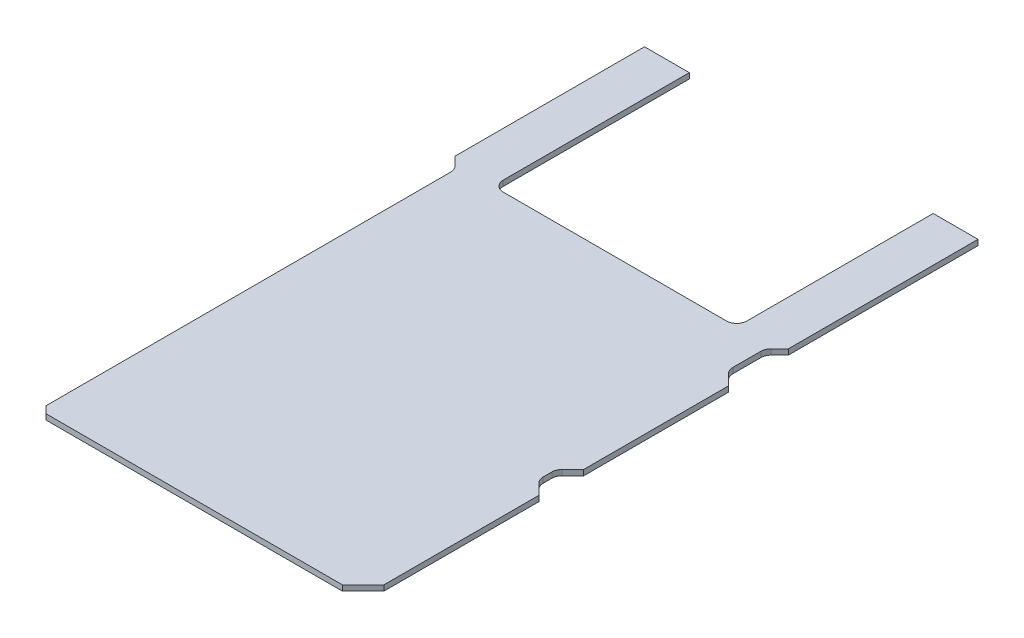
from build123d import *

# Parameters (mm, degrees)
SKETCH1_W           = 90
SKETCH1_H           = 177
BOSS_EXTRUDE1_DEPTH = 1.6
BOSS_EXTRUDE4_DEPTH = 1.6
BOSS_EXTRUDE5_DEPTH = 1.6
SKETCH9_W           = 70.7486
SKETCH9_H           = 57
CUT_EXTRUDE3_DEPTH  = 2.6
FILLET1_R           = 3


with BuildPart() as part:
    # Sketch1 → Boss-Extrude1 (new body)
    with BuildSketch(Plane(origin=(0, 0, 0), x_dir=(1, 0, 0), z_dir=(0, 1, 0))):
        Rectangle(SKETCH1_W, SKETCH1_H)
    extrude(amount=BOSS_EXTRUDE1_DEPTH)

    # Sketch7 → Boss-Extrude4 (add)
    with BuildSketch(Plane.XZ):
        Polygon((-45, -88.5), (-45, -30.1257), (-48.3743, -33.5), (-48.3743, -88.5), align=None)
        Polygon((45, -30.1257), (45, -88.5), (48.3743, -88.5), (48.3743, -33.5), align=None)
    extrude(amount=-BOSS_EXTRUDE4_DEPTH)

    # Sketch w → Boss-Extrude5 (add)
    with BuildSketch(Plane(origin=(0, 1.6, 0), x_dir=(1, 0, 0), z_dir=(0, 1, 0))):
        Polygon((-43, -90.5), (43, -90.5), (45, -88.5), (-45, -88.5), align=None)
        Polygon((45, -35.5), (45, -88.5), (49, -84.5), (49, -39.5), align=None)
        Polygon((45, 19.5), (45, -30.5), (49, -26.5), (49, 15.5), align=None)
    extrude(amount=-BOSS_EXTRUDE5_DEPTH)

    # Sketch9 → Cut-Extrude3 (cut, through all)
    with BuildSketch(Plane.XZ):
        with Locations((0, -60)):
            Rectangle(SKETCH9_W, SKETCH9_H)
    extrude(amount=-CUT_EXTRUDE3_DEPTH, mode=Mode.SUBTRACT)

    # Fillet1
    fillet1_edges = [part.edges().sort_by_distance(p)[0] for p in [
        (-45, 0.8, -30.1257),
        (45, 0.8, -30.1257),
        (45, 0.8, 35.5),
        (45, 0.8, 30.5),
        (45, 0.8, -19.5),
        (-35.3743, 0.8, -31.5),
        (35.3743, 0.8, -31.5),
    ]]
    fillet(fillet1_edges, radius=FILLET1_R)


solid = part.part
